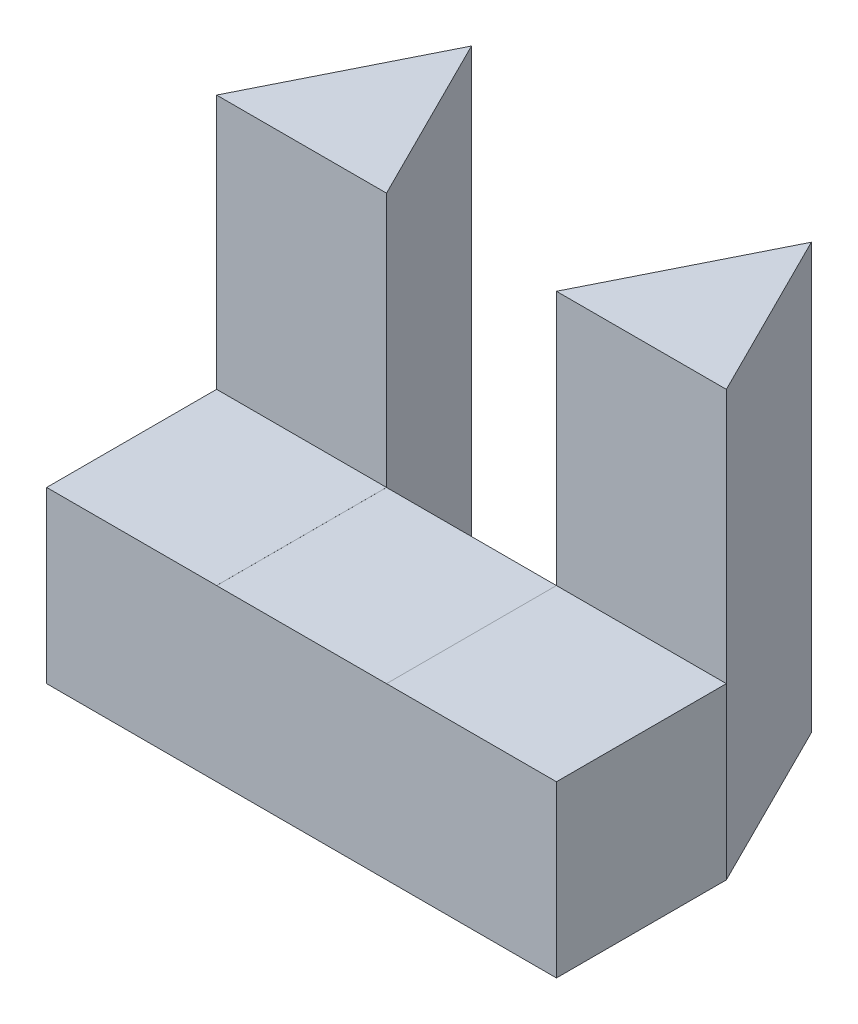
from build123d import *

# Parameters (mm, degrees)
BOSS_EXTRUDE1_DEPTH = 5
SKETCH2_W           = 2
SKETCH2_H           = 3
CUT_EXTRUDE1_DEPTH  = 5
SKETCH3_W           = 2
SKETCH3_H           = 2.999556198
CUT_EXTRUDE2_DEPTH  = 15


with BuildPart() as part:
    # Sketch1 → Boss-Extrude1 (new body)
    with BuildSketch(Plane(origin=(0, 0, 0), x_dir=(1, 0, 0), z_dir=(0, 1, 0))):
        Polygon((0, 0), (6, 0), (6, 2), (5, 4), (4, 2), (2, 2), (1, 4), (0, 2), align=None)
    extrude(amount=BOSS_EXTRUDE1_DEPTH)

    # Sketch2 → Cut-Extrude1 (cut)
    with BuildSketch(Plane.XY):
        with Locations((3, 3.5)):
            Rectangle(SKETCH2_W, SKETCH2_H)
    extrude(amount=-CUT_EXTRUDE1_DEPTH, mode=Mode.SUBTRACT)

    # Sketch3 → Cut-Extrude2 (cut)
    with BuildSketch(Plane.ZY):
        with Locations((-1, 3.500221901)):
            Rectangle(SKETCH3_W, SKETCH3_H)
    extrude(amount=-CUT_EXTRUDE2_DEPTH, mode=Mode.SUBTRACT)


solid = part.part
